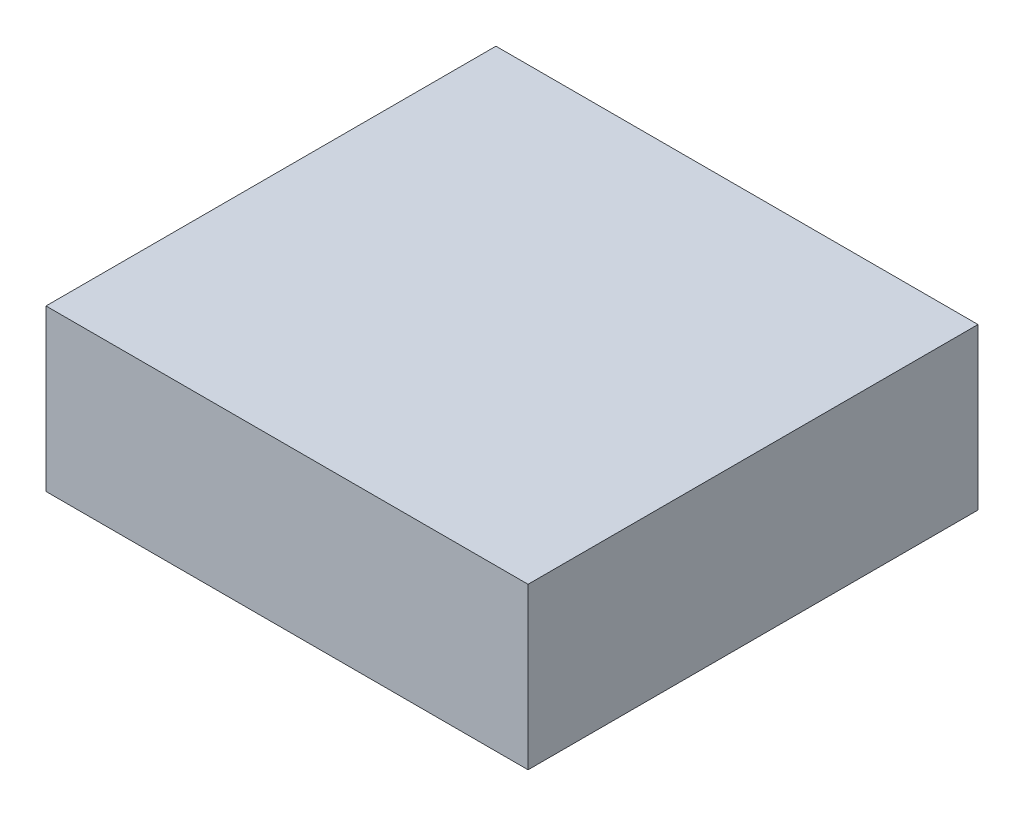
from build123d import *

# Parameters (mm, degrees)
SKETCH1_W           = 454.5
SKETCH1_H           = 424.2
BOSS_EXTRUDE1_DEPTH = 151.5


with BuildPart() as part:
    # Sketch1 → Boss-Extrude1 (new body)
    with BuildSketch(Plane(origin=(0, 0, 0), x_dir=(1, 0, 0), z_dir=(0, 1, 0))):
        Rectangle(SKETCH1_W, SKETCH1_H)
    extrude(amount=BOSS_EXTRUDE1_DEPTH)


solid = part.part
